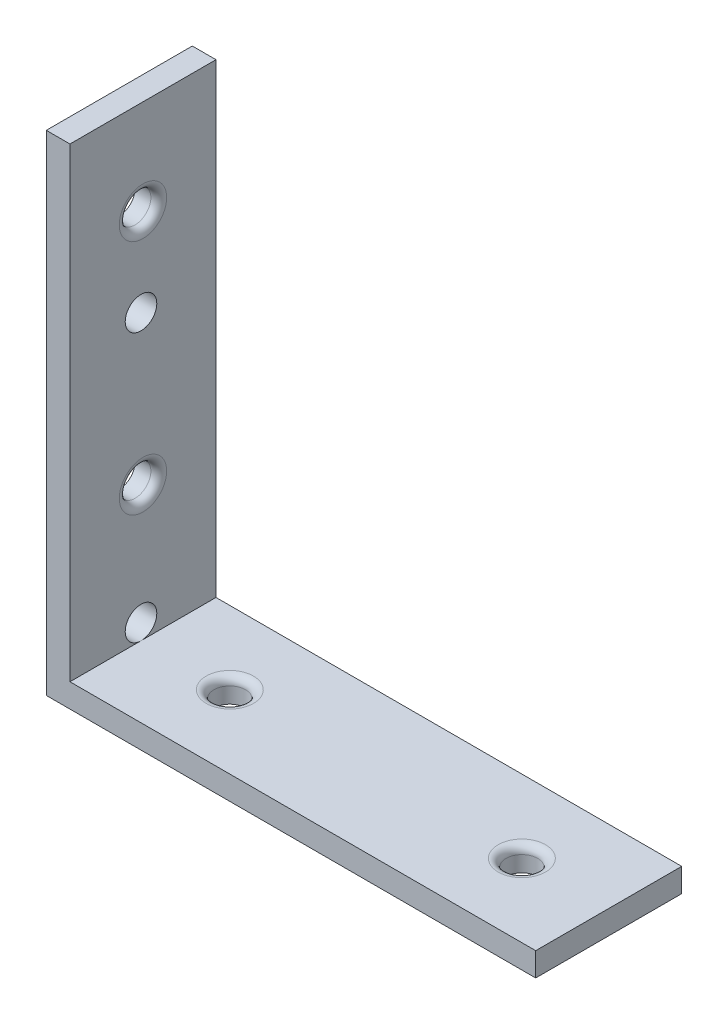
from build123d import *

# Parameters (mm, degrees)
SKETCH1_W           = 62
SKETCH1_H           = 62
BOSS_EXTRUDE1_DEPTH = 18.5
SKETCH2_W           = 59
SKETCH2_H           = 59
CUT_EXTRUDE1_DEPTH  = 18.5
SKETCH3_R           = 2
CUT_EXTRUDE2_DEPTH  = 3
SKETCH4_R           = 2
CUT_EXTRUDE3_DEPTH  = 3
FILLET1_R           = 1
FILLET2_R           = 1
SKETCH5_R           = 2
CUT_EXTRUDE4_DEPTH  = 3
SKETCH6_R           = 2
CUT_EXTRUDE5_DEPTH  = 3
FILLET3_R           = 1
FILLET4_R           = 1
SKETCH7_R           = 2
CUT_EXTRUDE6_DEPTH  = 3
SKETCH8_R           = 2
CUT_EXTRUDE7_DEPTH  = 3


with BuildPart() as part:
    # Sketch1 → Boss-Extrude1 (new body)
    with BuildSketch(Plane.XY):
        Rectangle(SKETCH1_W, SKETCH1_H)
    extrude(amount=BOSS_EXTRUDE1_DEPTH)

    # Sketch2 → Cut-Extrude1 (cut)
    with BuildSketch(Plane.XY.offset(18.5)):
        with Locations((1.5, 1.5)):
            Rectangle(SKETCH2_W, SKETCH2_H)
    extrude(amount=-CUT_EXTRUDE1_DEPTH, mode=Mode.SUBTRACT)

    # Sketch3 → Cut-Extrude2 (cut)
    with BuildSketch(Plane(origin=(0, -28, 0), x_dir=(1, 0, 0), z_dir=(0, 1, 0))):
        with Locations((-17, -9.25)):
            Circle(SKETCH3_R)
    extrude(amount=-CUT_EXTRUDE2_DEPTH, mode=Mode.SUBTRACT)

    # Sketch4 → Cut-Extrude3 (cut)
    with BuildSketch(Plane(origin=(0, -28, 0), x_dir=(1, 0, 0), z_dir=(0, 1, 0))):
        with Locations((20, -9.25)):
            Circle(SKETCH4_R)
    extrude(amount=-CUT_EXTRUDE3_DEPTH, mode=Mode.SUBTRACT)

    # Fillet1
    fillet1_edges = [part.edges().sort_by_distance(p)[0] for p in [
        (18, -28, 9.25),
    ]]
    fillet(fillet1_edges, radius=FILLET1_R)

    # Fillet2
    fillet2_edges = [part.edges().sort_by_distance(p)[0] for p in [
        (-19, -28, 9.25),
    ]]
    fillet(fillet2_edges, radius=FILLET2_R)

    # Sketch5 → Cut-Extrude4 (cut)
    with BuildSketch(Plane(origin=(-28, 0, 0), x_dir=(0, 0, -1), z_dir=(1, 0, 0))):
        with Locations((-9.25, -11)):
            Circle(SKETCH5_R)
    extrude(amount=-CUT_EXTRUDE4_DEPTH, mode=Mode.SUBTRACT)

    # Sketch6 → Cut-Extrude5 (cut)
    with BuildSketch(Plane(origin=(-28, 0, 0), x_dir=(0, 0, -1), z_dir=(1, 0, 0))):
        with Locations((-9.25, 19)):
            Circle(SKETCH6_R)
    extrude(amount=-CUT_EXTRUDE5_DEPTH, mode=Mode.SUBTRACT)

    # Fillet3
    fillet3_edges = [part.edges().sort_by_distance(p)[0] for p in [
        (-28, 19, 11.25),
    ]]
    fillet(fillet3_edges, radius=FILLET3_R)

    # Fillet4
    fillet4_edges = [part.edges().sort_by_distance(p)[0] for p in [
        (-28, -11, 11.25),
    ]]
    fillet(fillet4_edges, radius=FILLET4_R)

    # Sketch7 → Cut-Extrude6 (cut)
    with BuildSketch(Plane(origin=(-28, 0, 0), x_dir=(0, 0, -1), z_dir=(1, 0, 0))):
        with Locations((-9.5, -26)):
            Circle(SKETCH7_R)
    extrude(amount=-CUT_EXTRUDE6_DEPTH, mode=Mode.SUBTRACT)

    # Sketch8 → Cut-Extrude7 (cut)
    with BuildSketch(Plane(origin=(-28, 0, 0), x_dir=(0, 0, -1), z_dir=(1, 0, 0))):
        with Locations((-9.5, 8)):
            Circle(SKETCH8_R)
    extrude(amount=-CUT_EXTRUDE7_DEPTH, mode=Mode.SUBTRACT)


solid = part.part
